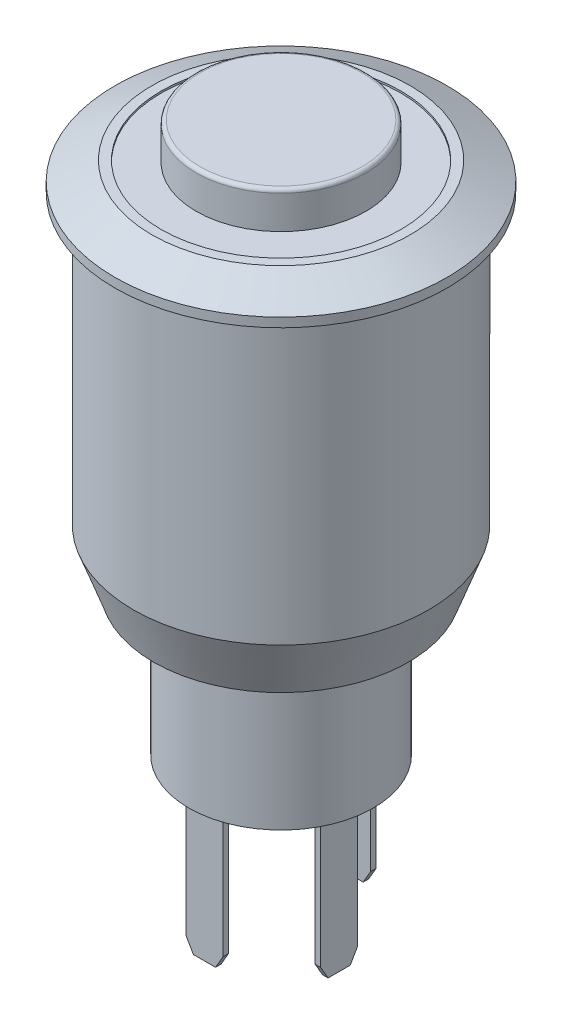
from build123d import *

# Parameters (mm, degrees)
FILLET1_R             = 0.2
SKETCH2_R             = 6.5
SKETCH2_R_2           = 4.6
CUT_EXTRUDE1_DEPTH    = 0.1
SKETCH3_W             = 2
SKETCH3_H             = 0.3
SKETCH3_W_2           = 0.3
SKETCH3_H_2           = 2
EXTRUDE_THIN1_DEPTH   = 7.6
CHAMFER1_SIZE         = 0.4
CHAMFER1_SIZE2        = 0.692820323
CHAMFER1_PART_2_SIZE  = 0.4
CHAMFER1_PART_2_SIZE2 = 0.692820323
CHAMFER1_PART_3_SIZE  = 0.4
CHAMFER1_PART_3_SIZE2 = 0.692820323
CHAMFER1_PART_4_SIZE  = 0.4
CHAMFER1_PART_4_SIZE2 = 0.692820323
CHAMFER2_SIZE         = 3
CHAMFER2_SIZE2        = 1.091910703


with BuildPart() as part:
    # Sketch1 → Revolve1 (revolve)
    with BuildSketch(Plane(origin=(0, 0, 0), x_dir=(0, 0, -1), z_dir=(1, 0, 0))):
        Polygon((0, 3.4), (-4.6, 3.4), (-4.6, 1.5), (-7, 1.5), (-9, 0.5), (-9, 0), (-8, 0), (-8, -18.6), (-5, -18.6), (-5, -26.4), (0, -26.4), align=None)
    revolve(axis=Axis((0, 14.375, 0), (0, -1, 0)))

    # Fillet1
    fillet1_edges = [part.edges().sort_by_distance(p)[0] for p in [
        (0, 3.4, -4.6),
    ]]
    fillet(fillet1_edges, radius=FILLET1_R)

    # Sketch2 → Cut-Extrude1 (cut)
    with BuildSketch(Plane(origin=(0, 1.5, 0), x_dir=(1, 0, 0), z_dir=(0, 1, 0))):
        Circle(SKETCH2_R)
        Circle(SKETCH2_R_2, mode=Mode.SUBTRACT)
    extrude(amount=-CUT_EXTRUDE1_DEPTH, mode=Mode.SUBTRACT)

    # Sketch3 → Extrude-Thin1 (add)
    with BuildSketch(Plane.XZ.offset(26.4)):
        with Locations((0, 4)):
            Rectangle(SKETCH3_W, SKETCH3_H)
        with Locations((0, -4)):
            Rectangle(SKETCH3_W, SKETCH3_H)
        with Locations((-4, 0)):
            Rectangle(SKETCH3_W_2, SKETCH3_H_2)
        with Locations((4, 1)):
            Rectangle(SKETCH3_W_2, SKETCH3_H_2)
    extrude(amount=EXTRUDE_THIN1_DEPTH)

    # Chamfer1
    chamfer1_edges = [part.edges().sort_by_distance(p)[0] for p in [
        (1, -34, 4),
        (-1, -34, 4),
    ]]
    chamfer1_side = [part.faces().sort_by_distance(p)[0] for p in [
        (0, -34, 4),
    ]]
    chamfer(chamfer1_edges, length=CHAMFER1_SIZE, length2=CHAMFER1_SIZE2, reference=chamfer1_side[0])

    # Chamfer1 part 2
    chamfer1_part_2_edges = [part.edges().sort_by_distance(p)[0] for p in [
        (1, -34, -4),
        (-1, -34, -4),
    ]]
    chamfer1_part_2_side = [part.faces().sort_by_distance(p)[0] for p in [
        (0, -34, -4),
    ]]
    chamfer(chamfer1_part_2_edges, length=CHAMFER1_PART_2_SIZE, length2=CHAMFER1_PART_2_SIZE2, reference=chamfer1_part_2_side[0])

    # Chamfer1 part 3
    chamfer1_part_3_edges = [part.edges().sort_by_distance(p)[0] for p in [
        (-4, -34, -1),
        (-4, -34, 1),
    ]]
    chamfer1_part_3_side = [part.faces().sort_by_distance(p)[0] for p in [
        (-4, -34, 0),
    ]]
    chamfer(chamfer1_part_3_edges, length=CHAMFER1_PART_3_SIZE, length2=CHAMFER1_PART_3_SIZE2, reference=chamfer1_part_3_side[0])

    # Chamfer1 part 4
    chamfer1_part_4_edges = [part.edges().sort_by_distance(p)[0] for p in [
        (4, -34, 2),
        (4, -34, 0),
    ]]
    chamfer1_part_4_side = [part.faces().sort_by_distance(p)[0] for p in [
        (4, -34, 1),
    ]]
    chamfer(chamfer1_part_4_edges, length=CHAMFER1_PART_4_SIZE, length2=CHAMFER1_PART_4_SIZE2, reference=chamfer1_part_4_side[0])

    # Chamfer2
    chamfer2_edges = [part.edges().sort_by_distance(p)[0] for p in [
        (0, -18.6, -8),
    ]]
    chamfer2_side = [part.faces().sort_by_distance(p)[0] for p in [
        (0, -9.3, -8),
    ]]
    chamfer(chamfer2_edges, length=CHAMFER2_SIZE, length2=CHAMFER2_SIZE2, reference=chamfer2_side[0])


solid = part.part
